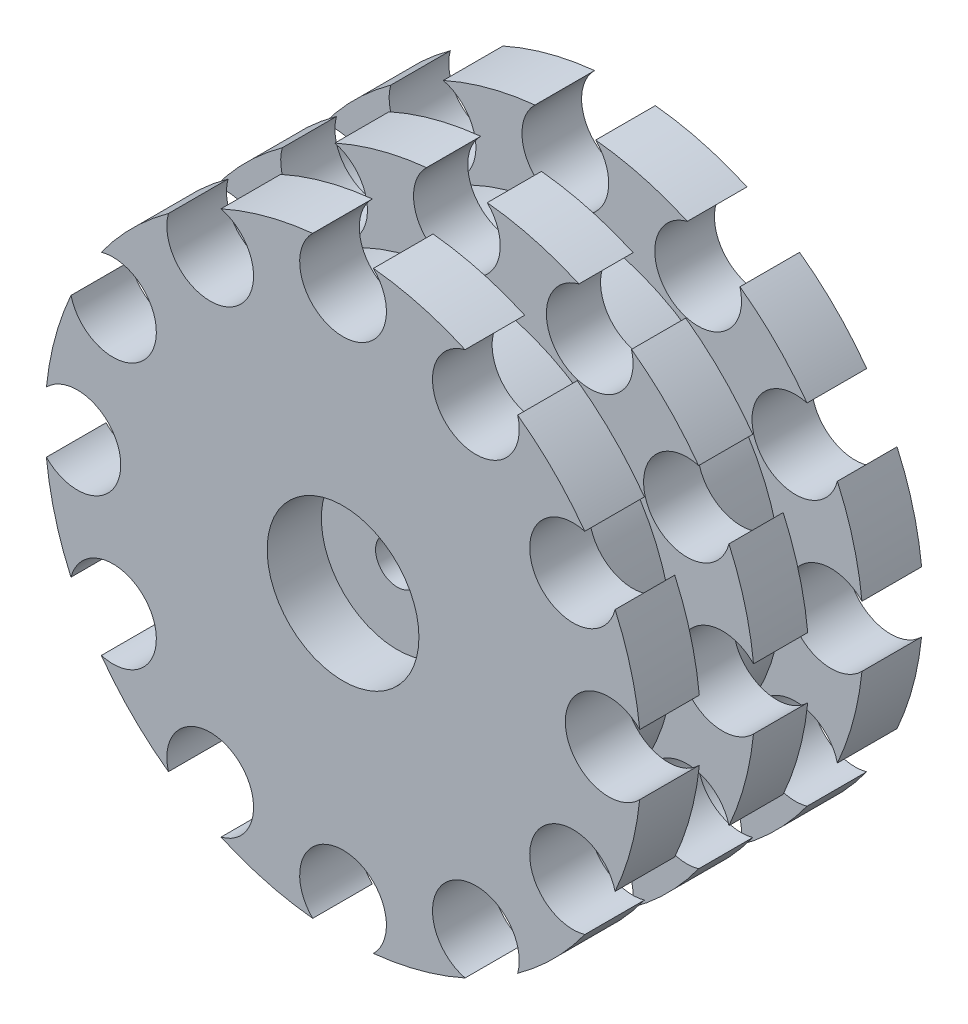
from build123d import *

# Parameters (mm, degrees)
CORTAR_EXTRUIR1_DEPTH   = 9
CROQUIS5_R              = 4
CORTAR_EXTRUIR3_DEPTH   = 27
CROQUIS6_R              = 2
CORTAR_EXTRUIR4_DEPTH   = 10
CROQUIS7_R              = 2
SALIENTE_EXTRUIR1_DEPTH = 1.5
CROQUIS8_R              = 7
CROQUIS8_R_2            = 2
CORTAR_EXTRUIR5_DEPTH   = 1.5


with BuildPart() as part:
    # Croquis1 → Revolución1 (revolve)
    with BuildSketch(Plane(origin=(0, 0, 0), x_dir=(1, 0, 0), z_dir=(0, 1, 0))):
        Polygon((0, 1.5), (0, -9.5), (7, -9.5), (7, -13), (12.5, -13), (27.5, -13), (27.5, -7.5), (20, -7.5), (20, -2.5), (27.5, -2.5), (27.5, 2.5), (20, 2.5), (20, 7.5), (27.5, 7.5), (27.5, 13), (12.5, 13), (12.5, 6.5), (7.5, 1.5), align=None)
    revolve(axis=Axis((0, 0, 0), (0, 0, -1)))

    # Croquis2 → Cortar-Extruir1 (cut)
    with BuildSketch(Plane(origin=(0, 0, -1.5), x_dir=(-1, 0, 0), z_dir=(0, 0, -1))):
        Polygon((7.505553499, 0), (3.75277675, 6.5), (-3.75277675, 6.5), (-7.505553499, 0), (-3.75277675, -6.5), (3.75277675, -6.5), align=None)
    extrude(amount=-CORTAR_EXTRUIR1_DEPTH, mode=Mode.SUBTRACT)

    # Croquis5 → Cortar-Extruir3 (cut, through all)
    with BuildSketch(Plane.XY.offset(13)):
        with Locations((0, 24.5)):
            Circle(CROQUIS5_R)
        with Locations((12.25, 21.217622393)):
            Circle(CROQUIS5_R)
        with Locations((21.217622393, 12.25)):
            Circle(CROQUIS5_R)
        with Locations((24.5, 0)):
            Circle(CROQUIS5_R)
        with Locations((21.217622393, -12.25)):
            Circle(CROQUIS5_R)
        with Locations((12.25, -21.217622393)):
            Circle(CROQUIS5_R)
        with Locations((0, -24.5)):
            Circle(CROQUIS5_R)
        with Locations((-12.25, -21.217622393)):
            Circle(CROQUIS5_R)
        with Locations((-21.217622393, -12.25)):
            Circle(CROQUIS5_R)
        with Locations((-24.5, 0)):
            Circle(CROQUIS5_R)
        with Locations((-21.217622393, 12.25)):
            Circle(CROQUIS5_R)
        with Locations((-12.25, 21.217622393)):
            Circle(CROQUIS5_R)
    extrude(amount=-CORTAR_EXTRUIR3_DEPTH, mode=Mode.SUBTRACT)

    # Croquis6 → Cortar-Extruir4 (cut)
    with BuildSketch(Plane(origin=(0, 0, 7.5), x_dir=(-1, 0, 0), z_dir=(0, 0, -1))):
        Circle(CROQUIS6_R)
    extrude(amount=-CORTAR_EXTRUIR4_DEPTH, mode=Mode.SUBTRACT)

    # Croquis7 → Saliente-Extruir1 (add)
    with BuildSketch(Plane(origin=(0, 0, 7.5), x_dir=(-1, 0, 0), z_dir=(0, 0, -1))):
        Polygon((3.75277675, -6.5), (7.505553499, 0), (3.75277675, 6.5), (-3.75277675, 6.5), (-7.505553499, 0), (-3.75277675, -6.5), align=None)
        Circle(CROQUIS7_R, mode=Mode.SUBTRACT)
    extrude(amount=SALIENTE_EXTRUIR1_DEPTH)

    # Croquis8 → Cortar-Extruir5 (cut)
    with BuildSketch(Plane.XY.offset(9.5)):
        Circle(CROQUIS8_R)
        Circle(CROQUIS8_R_2, mode=Mode.SUBTRACT)
    extrude(amount=-CORTAR_EXTRUIR5_DEPTH, mode=Mode.SUBTRACT)


solid = part.part
